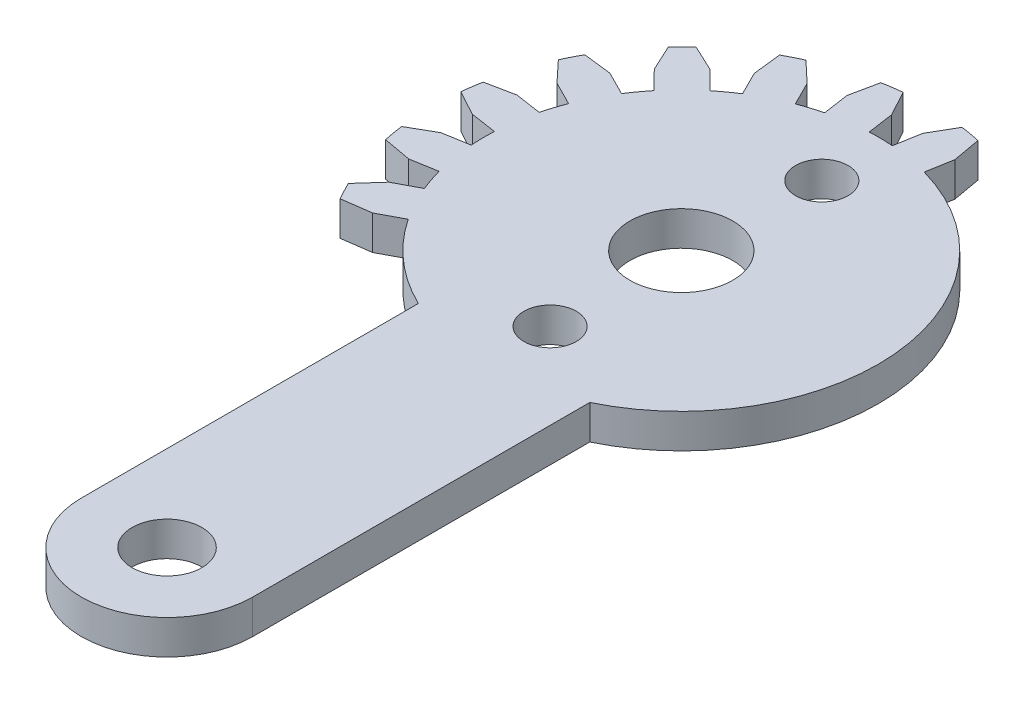
from build123d import *

# Parameters (mm, degrees)
CROQUIS1_R              = 2.034348523
CROQUIS1_R_2            = 3
SALIENTE_EXTRUIR1_DEPTH = 2
SALIENTE_EXTRUIR2_DEPTH = 2
MATRIZC1_COUNT          = 8
MATRIZC1_ANGLE          = 128
CROQUIS4_R              = 1.53
CORTAR_EXTRUIR1_DEPTH   = 10


with BuildPart() as part:
    # Croquis1 → Saliente-Extruir1 (new body)
    with BuildSketch(Plane(origin=(0, 0, 0), x_dir=(1, 0, 0), z_dir=(0, 1, 0))):
        with BuildLine():
            Line((-5, -10.339498295), (-5, -30))
            ThreePointArc((-5, -30), (0, -35), (5, -30))
            Line((5, -30), (5, -10.339498295))
            ThreePointArc((5, -10.339498295), (0, 11.485), (-5, -10.339498295))
        make_face()
        with Locations((0, -30)):
            Circle(CROQUIS1_R, mode=Mode.SUBTRACT)
        Circle(CROQUIS1_R_2, mode=Mode.SUBTRACT)
    extrude(amount=SALIENTE_EXTRUIR1_DEPTH)

    # Croquis3 → Saliente-Extruir2 (add)
    with BuildSketch(Plane(origin=(0, 0, 0), x_dir=(1, 0, 0), z_dir=(0, 1, 0))):
        with BuildLine():
            Line((1.120443051, 12.967936283), (0.853363456, 11.45325263))
            ThreePointArc((0.853363456, 11.45325263), (1.994349321, 11.310517043), (3.115343764, 11.054404472))
            Line((3.115343764, 11.054404472), (3.382423359, 12.569088125))
            Line((3.382423359, 12.569088125), (3.089673258, 14.215613789))
            ThreePointArc((3.089673258, 14.215613789), (2.526146865, 14.326490787), (1.958683104, 14.415037868))
            Line((1.958683104, 14.415037868), (1.120443051, 12.967936283))
        make_face()
    saliente_extruir2 = extrude(amount=SALIENTE_EXTRUIR2_DEPTH)

    # MatrizC1: Saliente-Extruir2 ×8 about axis
    matrizc1_axis = Axis((0, 0, 0), (0, 1, 0))
    for i in range(1, MATRIZC1_COUNT):
        add(saliente_extruir2.rotate(matrizc1_axis, i * MATRIZC1_ANGLE / (MATRIZC1_COUNT - 1)))

    # Croquis4 → Cortar-Extruir1 (cut)
    with BuildSketch(Plane.XZ):
        with Locations((0.559982615, -7.634490453)):
            Circle(CROQUIS4_R)
        with Locations((0, 7.655)):
            Circle(CROQUIS4_R)
    extrude(amount=-CORTAR_EXTRUIR1_DEPTH, mode=Mode.SUBTRACT)


solid = part.part
